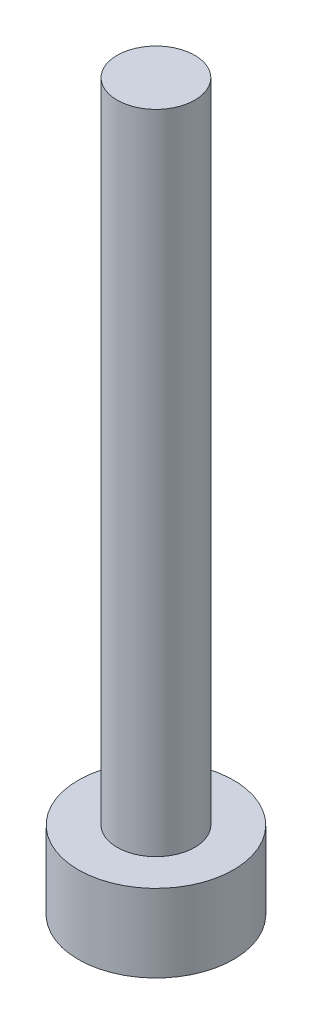
from build123d import *

# Parameters (mm, degrees)
SKETCH1_R           = 3
BOSS_EXTRUDE1_DEPTH = 3
SKETCH2_R           = 1.5
BOSS_EXTRUDE2_DEPTH = 25


with BuildPart() as part:
    # Sketch1 → Boss-Extrude1 (new body)
    with BuildSketch(Plane(origin=(0, 0, 0), x_dir=(1, 0, 0), z_dir=(0, 1, 0))):
        Circle(SKETCH1_R)
    extrude(amount=BOSS_EXTRUDE1_DEPTH)

    # Sketch2 → Boss-Extrude2 (add)
    with BuildSketch(Plane(origin=(0, 3, 0), x_dir=(1, 0, 0), z_dir=(0, 1, 0))):
        Circle(SKETCH2_R)
    extrude(amount=BOSS_EXTRUDE2_DEPTH)


solid = part.part
